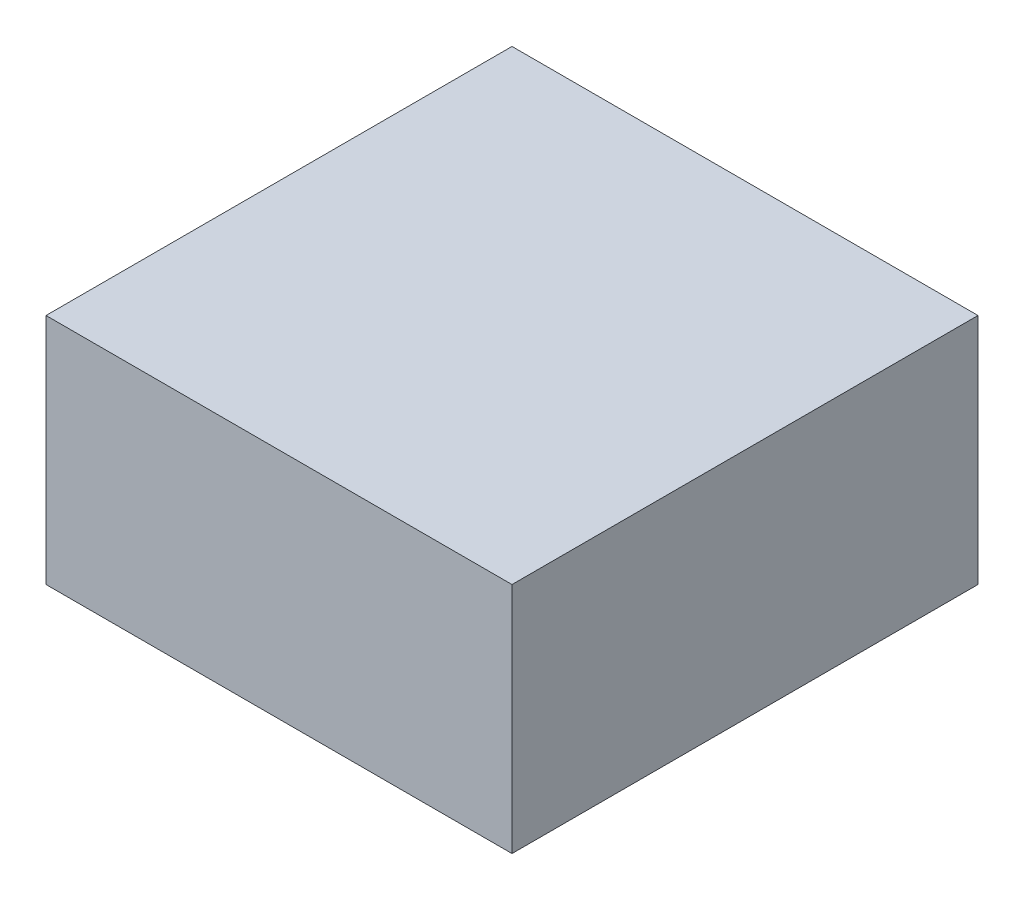
from build123d import *

# Parameters (mm, degrees)
SKETCH1_W           = 100
SKETCH1_H           = 50
BOSS_EXTRUDE1_DEPTH = 100


with BuildPart() as part:
    # Sketch1 → Boss-Extrude1 (new body)
    with BuildSketch(Plane.XY):
        Rectangle(SKETCH1_W, SKETCH1_H)
    extrude(amount=BOSS_EXTRUDE1_DEPTH)


solid = part.part
